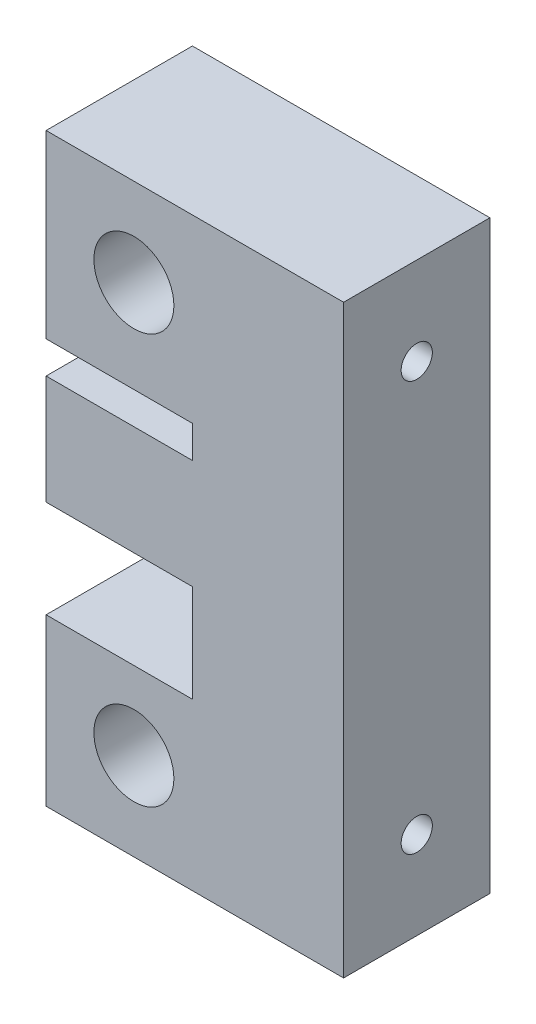
from build123d import *

# Parameters (mm, degrees)
SKETCH1_W           = 30.5
SKETCH1_H           = 15
BOSS_EXTRUDE1_DEPTH = 60
SKETCH2_R           = 4.1
CUT_EXTRUDE1_DEPTH  = 16
SKETCH4_W           = 15
SKETCH4_H           = 3.3
CUT_EXTRUDE2_DEPTH  = 16
SKETCH5_W           = 15
SKETCH5_H           = 10
CUT_EXTRUDE3_DEPTH  = 16
SKETCH6_R           = 1.6
CUT_EXTRUDE4_DEPTH  = 15


with BuildPart() as part:
    # Sketch1 → Boss-Extrude1 (new body)
    with BuildSketch(Plane(origin=(0, 0, 0), x_dir=(1, 0, 0), z_dir=(0, 1, 0))):
        Rectangle(SKETCH1_W, SKETCH1_H)
    extrude(amount=BOSS_EXTRUDE1_DEPTH)

    # Sketch2 → Cut-Extrude1 (cut, through all)
    with BuildSketch(Plane.XY.offset(7.5)):
        with Locations((-6.25, 51)):
            Circle(SKETCH2_R)
        with Locations((-6.25, 9)):
            Circle(SKETCH2_R)
    extrude(amount=-CUT_EXTRUDE1_DEPTH, mode=Mode.SUBTRACT)

    # Sketch4 → Cut-Extrude2 (cut, through all)
    with BuildSketch(Plane.XY.offset(7.5)):
        with Locations((-7.75, 39.85)):
            Rectangle(SKETCH4_W, SKETCH4_H)
    extrude(amount=-CUT_EXTRUDE2_DEPTH, mode=Mode.SUBTRACT)

    # Sketch5 → Cut-Extrude3 (cut, through all)
    with BuildSketch(Plane.XY.offset(7.5)):
        with Locations((-7.75, 22)):
            Rectangle(SKETCH5_W, SKETCH5_H)
    extrude(amount=-CUT_EXTRUDE3_DEPTH, mode=Mode.SUBTRACT)

    # Sketch6 → Cut-Extrude4 (cut)
    with BuildSketch(Plane(origin=(15.25, 0, 0), x_dir=(0, 0, -1), z_dir=(1, 0, 0))):
        with Locations((0, 51)):
            Circle(SKETCH6_R)
        with Locations((0, 9)):
            Circle(SKETCH6_R)
    extrude(amount=-CUT_EXTRUDE4_DEPTH, mode=Mode.SUBTRACT)


solid = part.part
